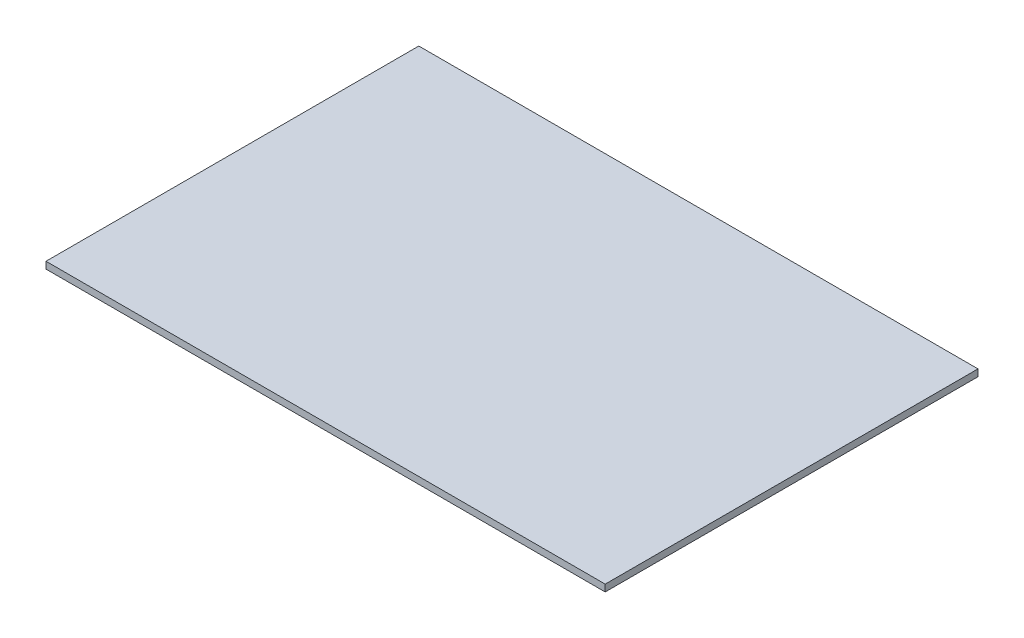
from build123d import *

# Parameters (mm, degrees)
SKETCH1_W           = 246
SKETCH1_H           = 164
BOSS_EXTRUDE1_DEPTH = 3


with BuildPart() as part:
    # Sketch1 → Boss-Extrude1 (new body)
    with BuildSketch(Plane(origin=(0, 0, 0), x_dir=(1, 0, 0), z_dir=(0, 1, 0))):
        Rectangle(SKETCH1_W, SKETCH1_H)
    extrude(amount=BOSS_EXTRUDE1_DEPTH)


solid = part.part
